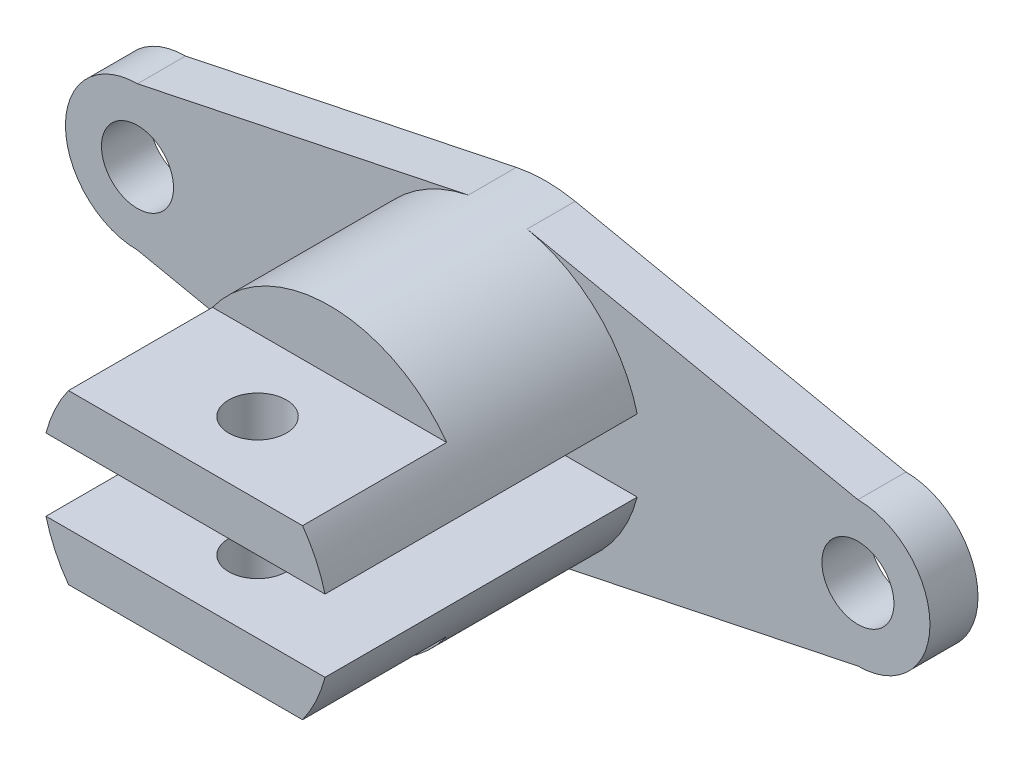
from build123d import *

# Parameters (mm, degrees)
SKETCH1_R               = 7.5
BOSS_EXTRUDE1_DEPTH     = 10
SKETCH2_R               = 30
BOSS_EXTRUDE2_DEPTH     = 65
CUT_EXTRUDE1_DEPTH      = 65
CUT_EXTRUDE2_DEPTH      = 30
SKETCH7_R               = 6
CUT_EXTRUDE3_DEPTH      = 13.5
CUT_EXTRUDE3_DEPTH_BACK = 48.5


with BuildPart() as part:
    # Sketch1 → Boss-Extrude1 (new body)
    with BuildSketch(Plane.XY):
        with BuildLine():
            Line((75, 15), (6.126443354, 29.36778323))
            ThreePointArc((6.126443354, 29.36778323), (0, 30), (-6.126443354, 29.36778323))
            Line((-6.126443354, 29.36778323), (-75, 15))
            ThreePointArc((-75, 15), (-90, 0), (-75, -15))
            Line((-75, -15), (-6.126443354, -29.36778323))
            ThreePointArc((-6.126443354, -29.36778323), (0, -30), (6.126443354, -29.36778323))
            Line((6.126443354, -29.36778323), (75, -15))
            ThreePointArc((75, -15), (90, 0), (75, 15))
        make_face()
        with Locations((75, 0)):
            Circle(SKETCH1_R, mode=Mode.SUBTRACT)
        with Locations((-75, 0)):
            Circle(SKETCH1_R, mode=Mode.SUBTRACT)
    extrude(amount=BOSS_EXTRUDE1_DEPTH)

    # Sketch2 → Boss-Extrude2 (add)
    with BuildSketch(Plane.XY.offset(10)):
        Circle(SKETCH2_R)
    extrude(amount=BOSS_EXTRUDE2_DEPTH)

    # Sketch3 → Cut-Extrude1 (cut)
    with BuildSketch(Plane.XY.offset(75)):
        with BuildLine():
            Line((-29.047375097, -7.5), (29.047375097, -7.5))
            ThreePointArc((29.047375097, -7.5), (30, 0), (29.047375097, 7.5))
            Line((29.047375097, 7.5), (-29.047375097, 7.5))
            ThreePointArc((-29.047375097, 7.5), (-30, 0), (-29.047375097, -7.5))
        make_face()
    extrude(amount=-CUT_EXTRUDE1_DEPTH, mode=Mode.SUBTRACT)

    # Sketch4 → Cut-Extrude2 (cut)
    with BuildSketch(Plane.XY.offset(75)):
        with BuildLine():
            Line((-24.366985862, -17.5), (24.366985862, -17.5))
            ThreePointArc((24.366985862, -17.5), (0, -30), (-24.366985862, -17.5))
        make_face()
        with BuildLine():
            Line((-24.366985862, 17.5), (24.366985862, 17.5))
            ThreePointArc((24.366985862, 17.5), (0, 30), (-24.366985862, 17.5))
        make_face()
    extrude(amount=-CUT_EXTRUDE2_DEPTH, mode=Mode.SUBTRACT)

    # Sketch7 → Cut-Extrude3 (cut, two sides)
    with BuildSketch(Plane.XZ.offset(17.5)) as cut_extrude3_sk:
        with Locations((0, 60)):
            Circle(SKETCH7_R)
    extrude(amount=CUT_EXTRUDE3_DEPTH, mode=Mode.SUBTRACT)
    extrude(cut_extrude3_sk.sketch, amount=-CUT_EXTRUDE3_DEPTH_BACK, mode=Mode.SUBTRACT)


solid = part.part
